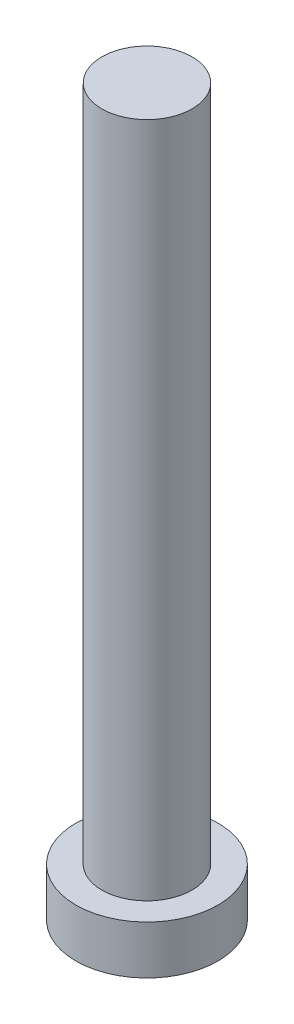
from build123d import *

# Parameters (mm, degrees)
SKETCH_1_R          = 3.15
EXTRUDE_1_DEPTH     = 2.15
SKETCH_2_R          = 2
EXTRUDE_2_DEPTH     = 30
CUT_EXTRUDE_1_DEPTH = 1.5


with BuildPart() as part:
    # 草图1 → 凸台-拉伸1 (new body)
    with BuildSketch(Plane(origin=(0, 0, 0), x_dir=(1, 0, 0), z_dir=(0, 1, 0))):
        Circle(SKETCH_1_R)
    extrude(amount=EXTRUDE_1_DEPTH)

    # 草图2 → 凸台-拉伸2 (add)
    with BuildSketch(Plane(origin=(0, 2.15, 0), x_dir=(1, 0, 0), z_dir=(0, 1, 0))):
        Circle(SKETCH_2_R)
    extrude(amount=EXTRUDE_2_DEPTH)

    # 草图3 → 切除-拉伸1 (cut)
    with BuildSketch(Plane.XZ):
        with BuildLine():
            Line((-0.5, 1), (-0.5, 2))
            Line((-0.5, 2), (0.5, 2))
            Line((0.5, 2), (0.5, 1))
            ThreePointArc((0.5, 1), (0.646446609, 0.646446609), (1, 0.5))
            Line((1, 0.5), (2, 0.5))
            Line((2, 0.5), (2, -0.5))
            Line((2, -0.5), (1, -0.5))
            ThreePointArc((1, -0.5), (0.646446609, -0.646446609), (0.5, -1))
            Line((0.5, -1), (0.5, -2))
            Line((0.5, -2), (-0.5, -2))
            Line((-0.5, -2), (-0.5, -1))
            ThreePointArc((-0.5, -1), (-0.646446609, -0.646446609), (-1, -0.5))
            Line((-1, -0.5), (-2, -0.5))
            Line((-2, -0.5), (-2, 0.5))
            Line((-2, 0.5), (-1, 0.5))
            ThreePointArc((-1, 0.5), (-0.646446609, 0.646446609), (-0.5, 1))
        make_face()
    extrude(amount=-CUT_EXTRUDE_1_DEPTH, mode=Mode.SUBTRACT)


solid = part.part
